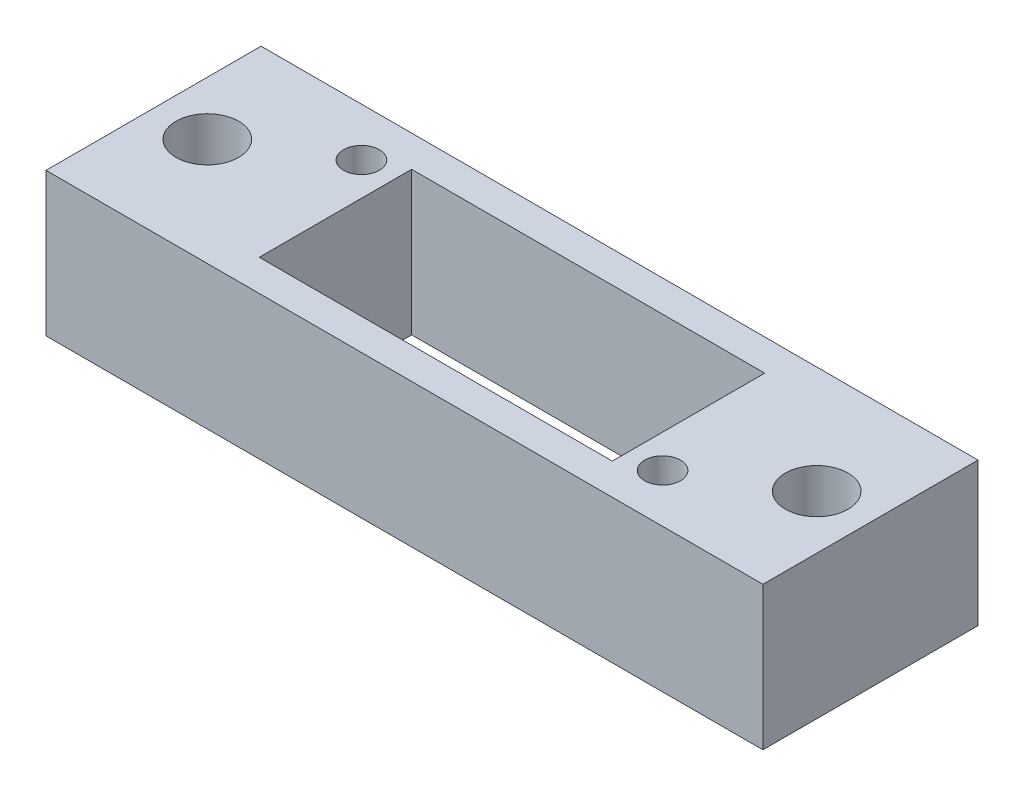
from build123d import *

# Parameters (mm, degrees)
SKETCH_1_W          = 40
SKETCH_1_H          = 12
EXTRUDE_1_DEPTH     = 8
SKETCH_2_W          = 19.7
SKETCH_2_H          = 8.5
CUT_EXTRUDE_1_DEPTH = 8
SKETCH_3_R          = 1
CUT_EXTRUDE_2_DEPTH = 8
SKETCH_4_R          = 1.75
CUT_EXTRUDE_3_DEPTH = 10


with BuildPart() as part:
    # 스케치1 → 보스-돌출1 (new body)
    with BuildSketch(Plane(origin=(0, 0, 0), x_dir=(1, 0, 0), z_dir=(0, 1, 0))):
        Rectangle(SKETCH_1_W, SKETCH_1_H)
    extrude(amount=EXTRUDE_1_DEPTH)

    # 스케치2 → 컷-돌출1 (cut)
    with BuildSketch(Plane(origin=(0, 8, 0), x_dir=(1, 0, 0), z_dir=(0, 1, 0))):
        Rectangle(SKETCH_2_W, SKETCH_2_H)
    extrude(amount=-CUT_EXTRUDE_1_DEPTH, mode=Mode.SUBTRACT)

    # 스케치3 → 컷-돌출2 (cut)
    with BuildSketch(Plane(origin=(0, 8, 0), x_dir=(1, 0, 0), z_dir=(0, 1, 0))):
        with Locations((-11.7, 3.3)):
            Circle(SKETCH_3_R)
        with Locations((11.7, -3.3)):
            Circle(SKETCH_3_R)
    extrude(amount=-CUT_EXTRUDE_2_DEPTH, mode=Mode.SUBTRACT)

    # 스케치4 → 컷-돌출3 (cut)
    with BuildSketch(Plane(origin=(0, 8, 0), x_dir=(1, 0, 0), z_dir=(0, 1, 0))):
        with Locations((-17, 0)):
            Circle(SKETCH_4_R)
        with Locations((17, 0)):
            Circle(SKETCH_4_R)
    extrude(amount=-CUT_EXTRUDE_3_DEPTH, mode=Mode.SUBTRACT)


solid = part.part
